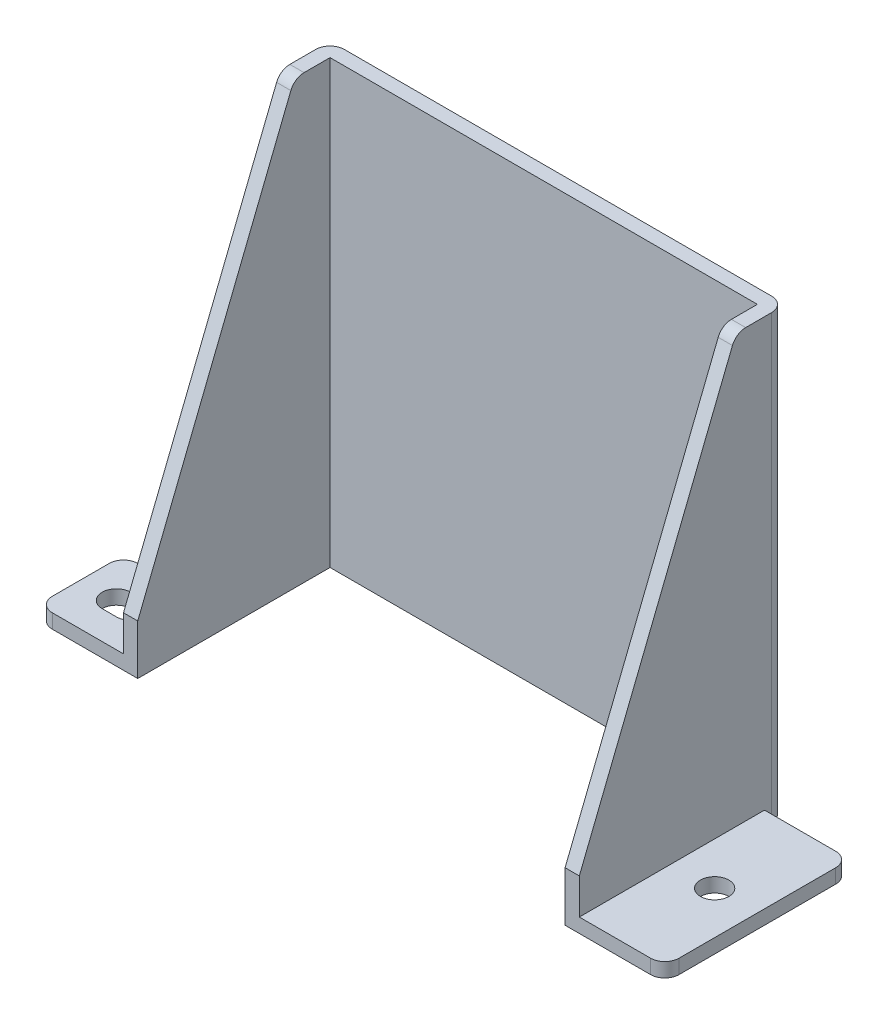
from build123d import *

# Parameters (mm, degrees)
SALIENTE_EXTRUIR1_DEPTH    = 2
SALIENTE_EXTRUIR2_DEPTH    = 60
CORTAR_EXTRUIR1_DEPTH      = 45
CORTAR_EXTRUIR1_DEPTH_BACK = 45
CROQUIS4_R                 = 2
CORTAR_EXTRUIR2_DEPTH      = 3
REDONDEO1_R                = 2


with BuildPart() as part:
    # Croquis1 → Saliente-Extruir1 (new body)
    with BuildSketch(Plane(origin=(0, 0, 0), x_dir=(1, 0, 0), z_dir=(0, 1, 0))):
        Polygon((-32, -2.5), (-32, 14.5), (32, 14.5), (32, 11.5), (44, 11.5), (44, -14.5), (30, -14.5), (30, 12.5), (-30, 12.5), (-30, -14.5), (-44, -14.5), (-44, -2.5), align=None)
    extrude(amount=SALIENTE_EXTRUIR1_DEPTH)

    # Croquis2 → Saliente-Extruir2 (add)
    with BuildSketch(Plane(origin=(0, 2, 0), x_dir=(1, 0, 0), z_dir=(0, 1, 0))):
        Polygon((-32, 14.5), (-32, -2.5), (-32, -14.5), (-30, -14.5), (-30, 12.5), (30, 12.5), (30, -14.5), (32, -14.5), (32, 14.5), align=None)
    extrude(amount=SALIENTE_EXTRUIR2_DEPTH)

    # Croquis3 → Cortar-Extruir1 (cut, two sides)
    with BuildSketch(Plane(origin=(0, 0, 0), x_dir=(0, 0, -1), z_dir=(1, 0, 0))) as cortar_extruir1_sk:
        Polygon((-14.5, 7), (7.5, 62), (-14.5, 62), align=None)
    extrude(amount=CORTAR_EXTRUIR1_DEPTH, mode=Mode.SUBTRACT)
    extrude(cortar_extruir1_sk.sketch, amount=-CORTAR_EXTRUIR1_DEPTH_BACK, mode=Mode.SUBTRACT)

    # Croquis4 → Cortar-Extruir2 (cut, through all)
    with BuildSketch(Plane(origin=(0, 2, 0), x_dir=(1, 0, 0), z_dir=(0, 1, 0))):
        with Locations((38, -1.5)):
            Circle(CROQUIS4_R)
        with BuildLine():
            Line((-39, -6.5), (-37, -6.5))
            ThreePointArc((-37, -6.5), (-35, -8.5), (-37, -10.5))
            Line((-37, -10.5), (-39, -10.5))
            ThreePointArc((-39, -10.5), (-41, -8.5), (-39, -6.5))
        make_face()
    extrude(amount=-CORTAR_EXTRUIR2_DEPTH, mode=Mode.SUBTRACT)

    # Redondeo1
    redondeo1_edges = [part.edges().sort_by_distance(p)[0] for p in [
        (44, 1, -11.5),
        (44, 1, 14.5),
        (-44, 1, 14.5),
        (-44, 1, 2.5),
        (-32, 31, -14.5),
        (32, 31, -14.5),
        (-31, 62, -7.5),
        (31, 62, -7.5),
    ]]
    fillet(redondeo1_edges, radius=REDONDEO1_R)


solid = part.part
